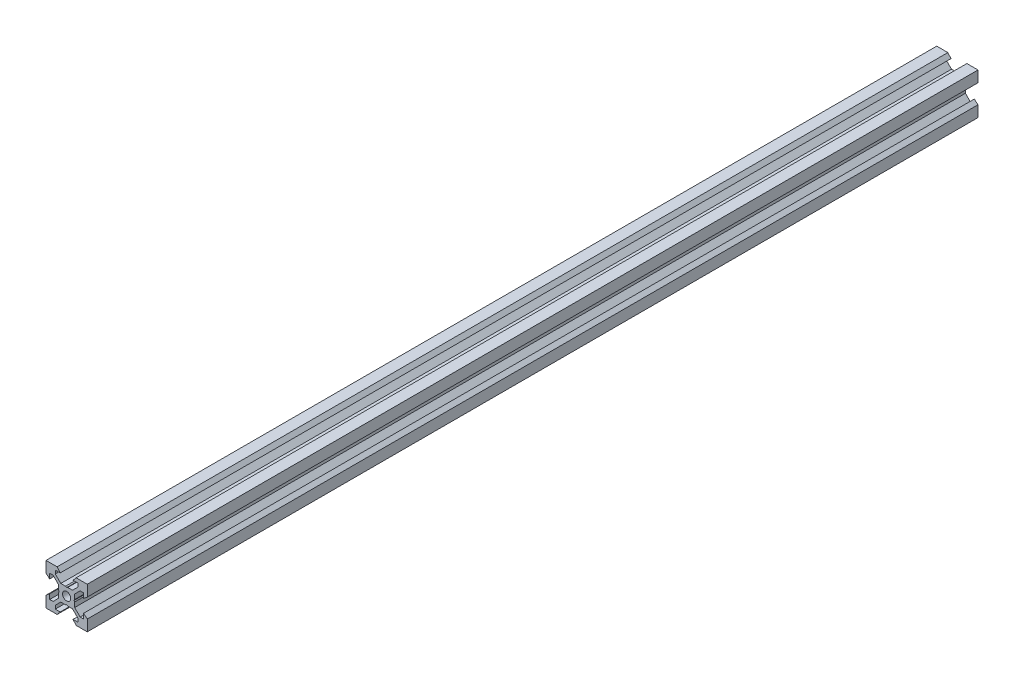
from build123d import *

# Parameters (mm, degrees)
SKETCH1_R           = 2
BOSS_EXTRUDE1_DEPTH = 215.87


with BuildPart() as part:
    # Sketch1 → Boss-Extrude1 (new body, symmetric)
    with BuildSketch(Plane.XY):
        Polygon((10, 10), (10, 4.610379336), (8.2, 3.1), (8.2, 5.5), (6.560660172, 5.5), (3.9, 2.839339828), (3.9, 0.519615242), (3.6, 0), (3.9, -0.519615242), (3.9, -2.839339828), (6.560660172, -5.5), (8.2, -5.5), (8.2, -3.1), (10, -4.610379336), (10, -10), (4.610379336, -10), (3.1, -8.2), (5.5, -8.2), (5.5, -6.560660172), (2.839339828, -3.9), (0.519615242, -3.9), (0, -3.6), (-0.519615242, -3.9), (-2.839339828, -3.9), (-5.5, -6.560660172), (-5.5, -8.2), (-3.1, -8.2), (-4.610379336, -10), (-10, -10), (-10, -4.610379336), (-8.2, -3.1), (-8.2, -5.5), (-6.560660172, -5.5), (-3.9, -2.839339828), (-3.9, -0.519615242), (-3.6, 0), (-3.9, 0.519615242), (-3.9, 2.839339828), (-6.560660172, 5.5), (-8.2, 5.5), (-8.2, 3.1), (-10, 4.610379336), (-10, 10), (-4.610379336, 10), (-3.1, 8.2), (-5.5, 8.2), (-5.5, 6.560660172), (-2.839339828, 3.9), (-0.519615242, 3.9), (0, 3.6), (0.519615242, 3.9), (2.839339828, 3.9), (5.5, 6.560660172), (5.5, 8.2), (3.1, 8.2), (4.610379336, 10), align=None)
        Circle(SKETCH1_R, mode=Mode.SUBTRACT)
    extrude(amount=BOSS_EXTRUDE1_DEPTH, both=True)


solid = part.part
